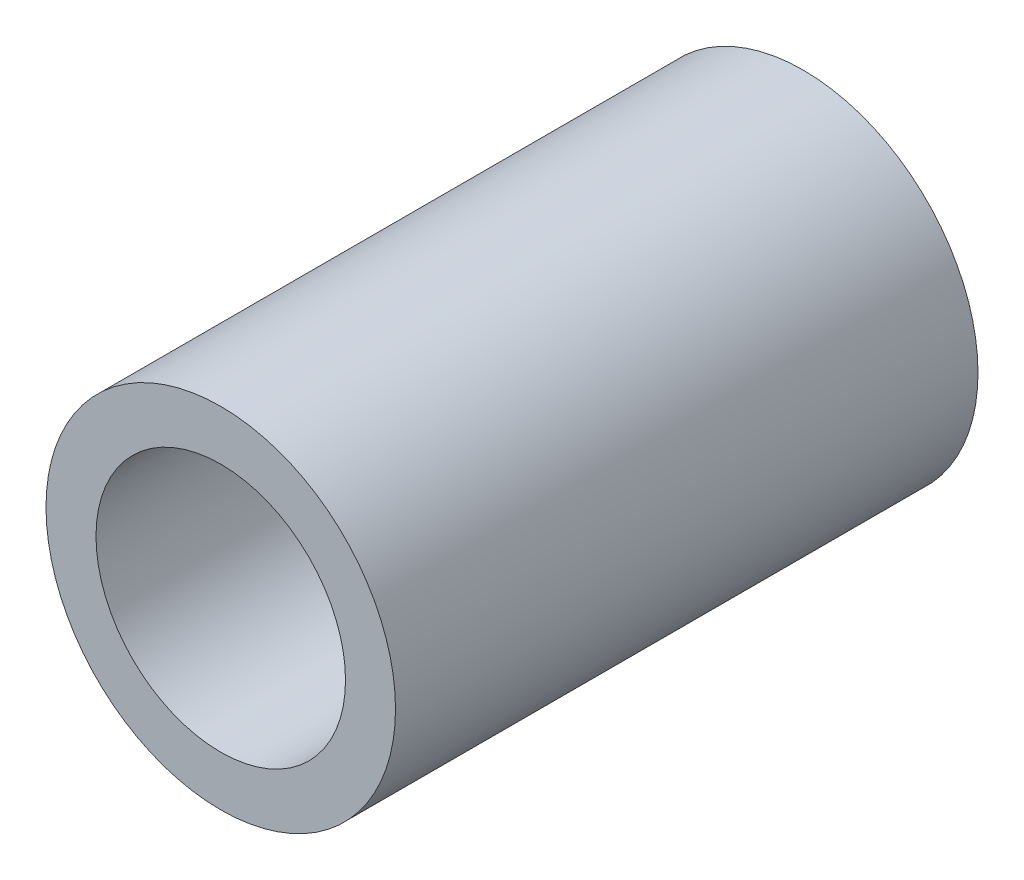
from build123d import *

# Parameters (mm, degrees)
SKETCH1_R           = 2.38125
SKETCH1_R_2         = 1.7
BOSS_EXTRUDE1_DEPTH = 3.96875


with BuildPart() as part:
    # Sketch1 → Boss-Extrude1 (new body, symmetric)
    with BuildSketch(Plane.XY):
        Circle(SKETCH1_R)
        Circle(SKETCH1_R_2, mode=Mode.SUBTRACT)
    extrude(amount=BOSS_EXTRUDE1_DEPTH, both=True)


solid = part.part
